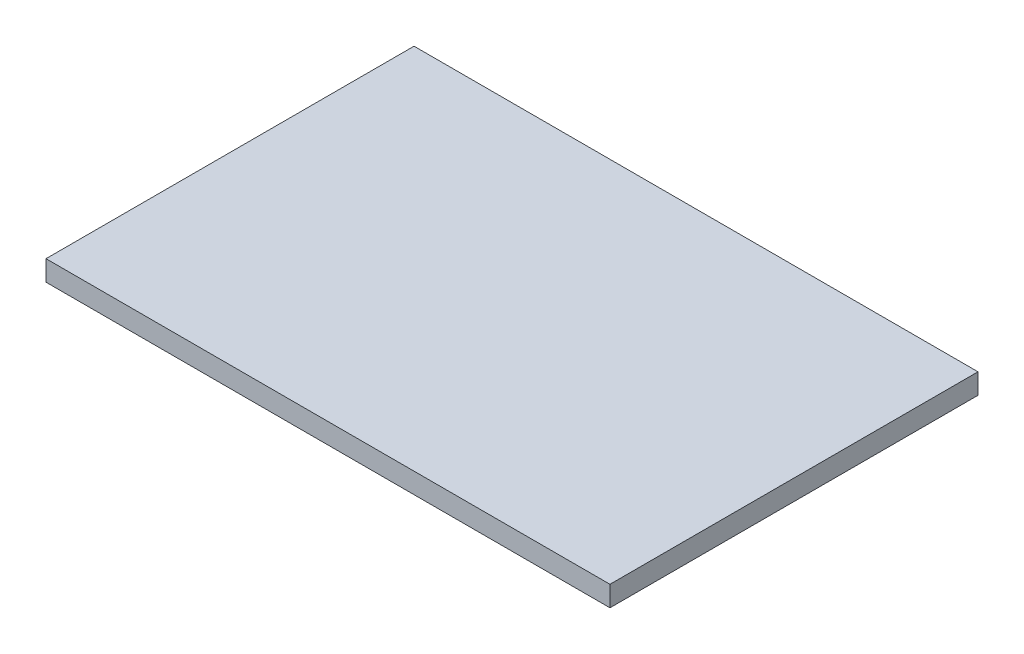
from build123d import *

# Parameters (mm, degrees)
SKETCH_1_W      = 498
SKETCH_1_H      = 325
EXTRUDE_1_DEPTH = 18


with BuildPart() as part:
    # Эскиз1 → Бобышка-Вытянуть1 (new body)
    with BuildSketch(Plane(origin=(0, 0, 0), x_dir=(1, 0, 0), z_dir=(0, 1, 0))):
        Rectangle(SKETCH_1_W, SKETCH_1_H)
    extrude(amount=EXTRUDE_1_DEPTH)


solid = part.part
